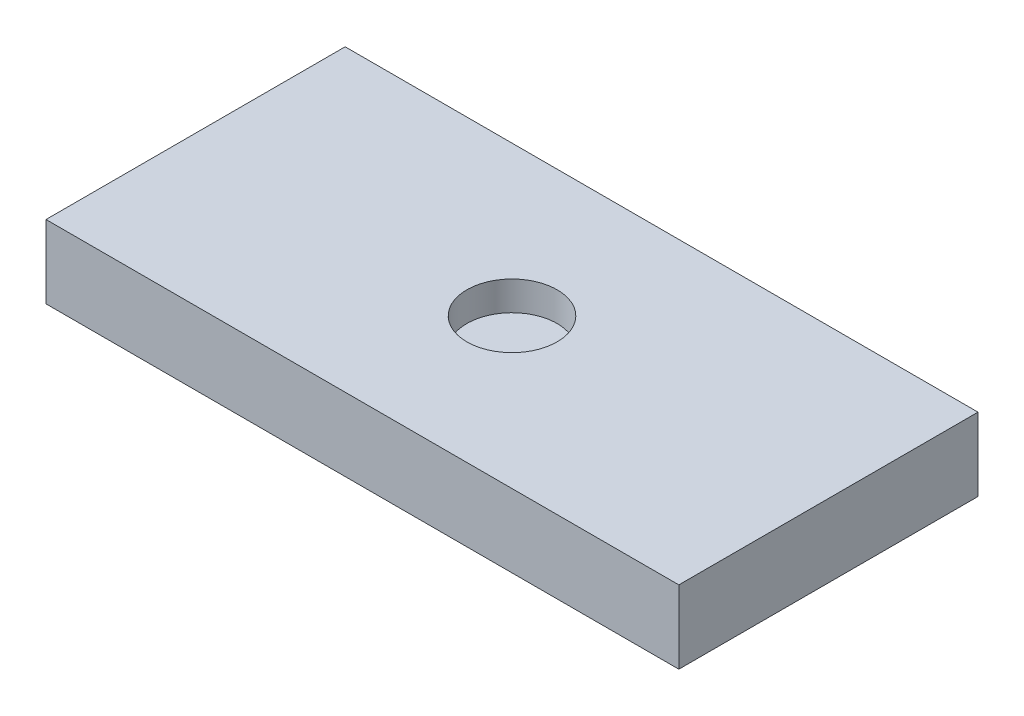
from build123d import *

# Parameters (mm, degrees)
SKETCH1_W           = 55
SKETCH1_H           = 26
BOSS_EXTRUDE1_DEPTH = 6.35
SKETCH2_R           = 3.923207931
CUT_EXTRUDE1_DEPTH  = 2.54


with BuildPart() as part:
    # Sketch1 → Boss-Extrude1 (new body)
    with BuildSketch(Plane(origin=(0, 0, 0), x_dir=(1, 0, 0), z_dir=(0, 1, 0))):
        Rectangle(SKETCH1_W, SKETCH1_H)
    extrude(amount=BOSS_EXTRUDE1_DEPTH)

    # Sketch2 → Cut-Extrude1 (cut)
    with BuildSketch(Plane(origin=(0, 6.35, 0), x_dir=(1, 0, 0), z_dir=(0, 1, 0))):
        Circle(SKETCH2_R)
    extrude(amount=-CUT_EXTRUDE1_DEPTH, mode=Mode.SUBTRACT)


solid = part.part
